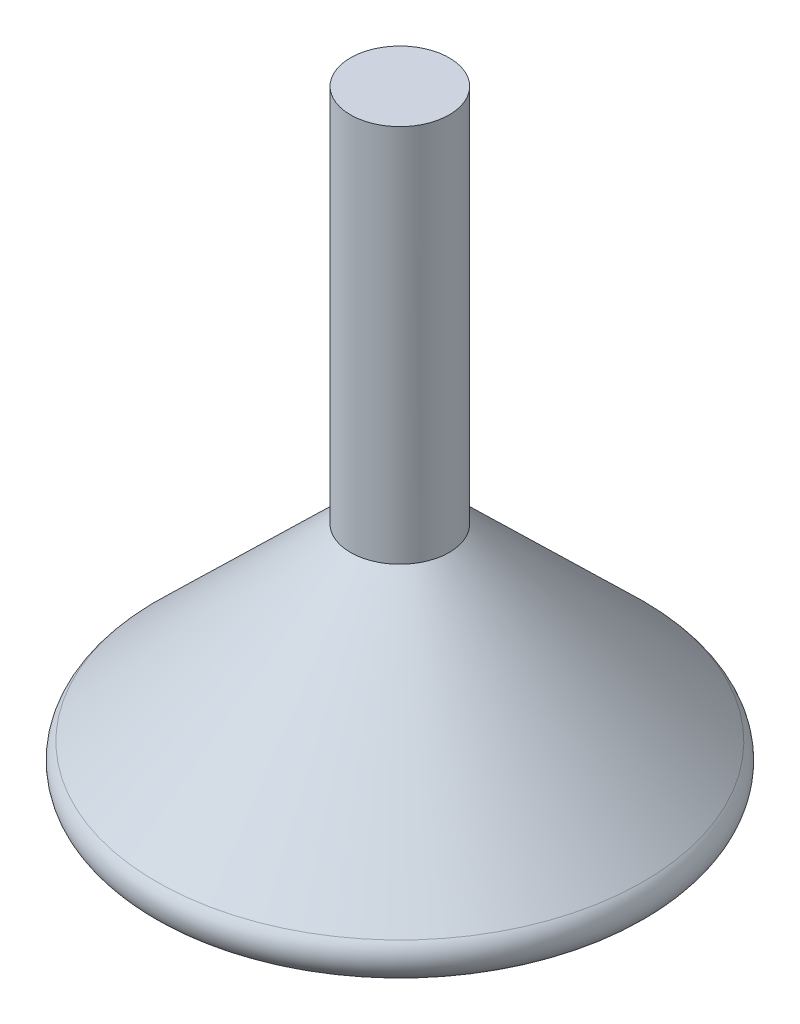
from build123d import *

# Parameters (mm, degrees)
SKETCH2_R           = 6.516376359
BOSS_EXTRUDE1_DEPTH = 50


with BuildPart() as part:
    # Sketch1 → Revolve1 (revolve)
    with BuildSketch(Plane.XY):
        with BuildLine():
            Line((32.090567685, 5.151633508), (6.516376359, 30))
            Line((6.516376359, 30), (0, 30))
            Line((0, 30), (0, 0))
            Line((0, 0), (30, 0))
            ThreePointArc((30, 0), (32.779829179, 1.871926537), (32.090567685, 5.151633508))
        make_face()
    revolve(axis=Axis((0, 27.622874036, 0), (0, 1, 0)))

    # Sketch2 → Boss-Extrude1 (add)
    with BuildSketch(Plane(origin=(0, 30, 0), x_dir=(1, 0, 0), z_dir=(0, 1, 0))):
        Circle(SKETCH2_R)
    extrude(amount=BOSS_EXTRUDE1_DEPTH)


solid = part.part
